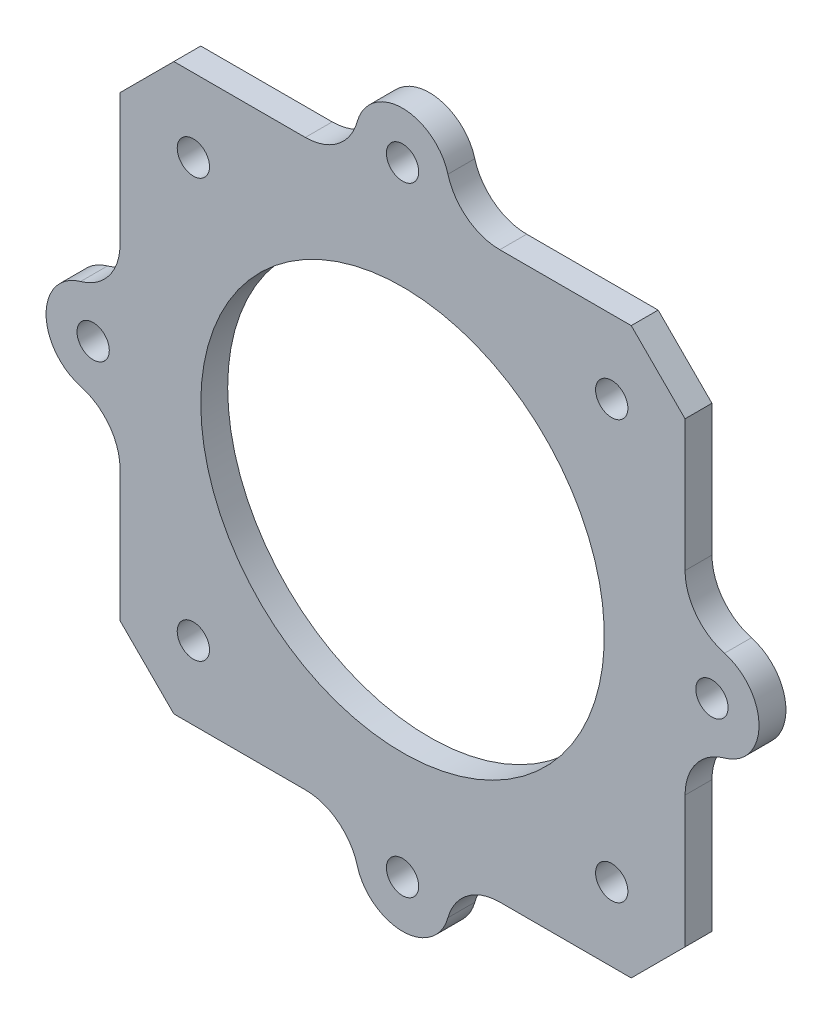
from build123d import *

# Parameters (mm, degrees)
SKETCH_1_W          = 42
SKETCH_1_H          = 42
EXTRUDE_1_DEPTH     = 2
CHAMFER_1_SIZE      = 4
SKETCH_2_R          = 1.2
CUT_EXTRUDE_1_DEPTH = 2.5
SKETCH_3_R          = 15
CUT_EXTRUDE_2_DEPTH = 2.5
SKETCH_4_R          = 1.2
EXTRUDE_2_DEPTH     = 2
FILLET_1_R          = 4


with BuildPart() as part:
    # 草图1 → 凸台-拉伸1 (new body)
    with BuildSketch(Plane.XY):
        Rectangle(SKETCH_1_W, SKETCH_1_H)
    extrude(amount=EXTRUDE_1_DEPTH)

    # 倒角1
    chamfer_1_edges = [part.edges().sort_by_distance(p)[0] for p in [
        (21, -21, 1),
        (-21, -21, 1),
        (-21, 21, 1),
        (21, 21, 1),
    ]]
    chamfer(chamfer_1_edges, length=CHAMFER_1_SIZE)

    # 草图2 → 切除-拉伸1 (cut)
    with BuildSketch(Plane(origin=(0, 0, 0), x_dir=(-1, 0, 0), z_dir=(0, 0, -1))):
        with Locations((-15.55, 15.55)):
            Circle(SKETCH_2_R)
        with Locations((15.55, 15.55)):
            Circle(SKETCH_2_R)
        with Locations((15.55, -15.55)):
            Circle(SKETCH_2_R)
        with Locations((-15.55, -15.55)):
            Circle(SKETCH_2_R)
    extrude(amount=-CUT_EXTRUDE_1_DEPTH, mode=Mode.SUBTRACT)

    # 草图3 → 切除-拉伸2 (cut)
    with BuildSketch(Plane(origin=(0, 0, 0), x_dir=(-1, 0, 0), z_dir=(0, 0, -1))):
        Circle(SKETCH_3_R)
    extrude(amount=-CUT_EXTRUDE_2_DEPTH, mode=Mode.SUBTRACT)

    # 草图4 → 凸台-拉伸2 (add)
    with BuildSketch(Plane.XY):
        with BuildLine():
            Line((3.5, 23), (3.5, 19))
            Line((3.5, 19), (-3.5, 19))
            Line((-3.5, 19), (-3.5, 23))
            ThreePointArc((-3.5, 23), (0, 26.5), (3.5, 23))
        make_face()
        with Locations((0, 23)):
            Circle(SKETCH_4_R, mode=Mode.SUBTRACT)
        with BuildLine():
            ThreePointArc((3.5, -23), (0, -26.5), (-3.5, -23))
            Line((-3.5, -23), (-3.5, -19))
            Line((-3.5, -19), (3.5, -19))
            Line((3.5, -19), (3.5, -23))
        make_face()
        with Locations((0, -23)):
            Circle(SKETCH_4_R, mode=Mode.SUBTRACT)
        with BuildLine():
            ThreePointArc((-23, -3.5), (-26.5, 0), (-23, 3.5))
            Line((-23, 3.5), (-19, 3.5))
            Line((-19, 3.5), (-19, -3.5))
            Line((-19, -3.5), (-23, -3.5))
        make_face()
        with Locations((-23, 0)):
            Circle(SKETCH_4_R, mode=Mode.SUBTRACT)
        with BuildLine():
            Line((19, -3.5), (23, -3.5))
            ThreePointArc((23, -3.5), (26.5, 0), (23, 3.5))
            Line((23, 3.5), (19, 3.5))
            Line((19, 3.5), (19, -3.5))
        make_face()
        with Locations((23, 0)):
            Circle(SKETCH_4_R, mode=Mode.SUBTRACT)
    extrude(amount=EXTRUDE_2_DEPTH)

    # 圆角1
    fillet_1_edges = [part.edges().sort_by_distance(p)[0] for p in [
        (-21, 3.5, 1),
        (-21, -3.5, 1),
        (-3.5, -21, 1),
        (3.5, -21, 1),
        (21, -3.5, 1),
        (21, 3.5, 1),
        (3.5, 21, 1),
        (-3.5, 21, 1),
    ]]
    fillet(fillet_1_edges, radius=FILLET_1_R)


solid = part.part
